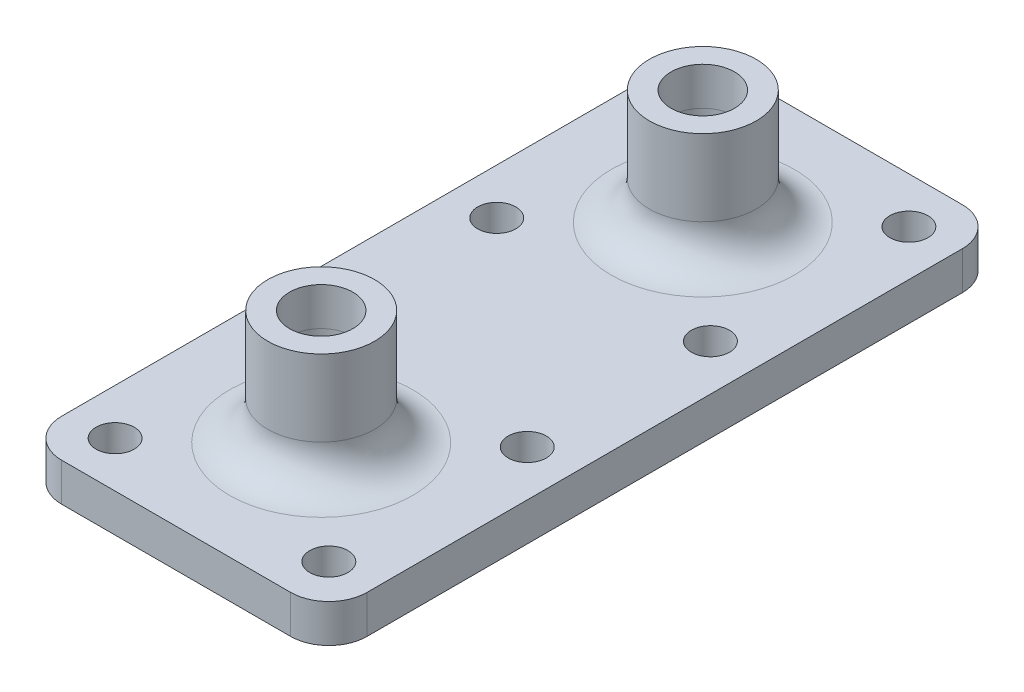
from build123d import *

# Parameters (mm, degrees)
SKETCH1_W             = 40
SKETCH1_H             = 88
SKETCH1_R             = 2.5
BOSS_EXTRUDE1_DEPTH   = 5
SKETCH2_R             = 7
SKETCH2_R_2           = 4.15
BOSS_EXTRUDE2_DEPTH   = 20
CHAMFER1_SIZE         = 10
CHAMFER1_SIZE2        = 0.174550649
CHAMFER1_PART_2_SIZE  = 10
CHAMFER1_PART_2_SIZE2 = 0.174550649
FILLET1_R             = 5


with BuildPart() as part:
    # Sketch1 → Boss-Extrude1 (new body)
    with BuildSketch(Plane(origin=(0, 0, 0), x_dir=(1, 0, 0), z_dir=(0, 1, 0))):
        Rectangle(SKETCH1_W, SKETCH1_H)
        with Locations((-14, 38)):
            Circle(SKETCH1_R, mode=Mode.SUBTRACT)
        with Locations((14, 38)):
            Circle(SKETCH1_R, mode=Mode.SUBTRACT)
        with Locations((-14, 12)):
            Circle(SKETCH1_R, mode=Mode.SUBTRACT)
        with Locations((14, 12)):
            Circle(SKETCH1_R, mode=Mode.SUBTRACT)
        with Locations((-14, -12)):
            Circle(SKETCH1_R, mode=Mode.SUBTRACT)
        with Locations((-14, -38)):
            Circle(SKETCH1_R, mode=Mode.SUBTRACT)
        with Locations((14, -38)):
            Circle(SKETCH1_R, mode=Mode.SUBTRACT)
        with Locations((14, -12)):
            Circle(SKETCH1_R, mode=Mode.SUBTRACT)
    extrude(amount=BOSS_EXTRUDE1_DEPTH)

    # Sketch2 → Boss-Extrude2 (add)
    with BuildSketch(Plane(origin=(0, 0, 0), x_dir=(1, 0, 0), z_dir=(0, 1, 0))):
        with Locations((0, 25)):
            Circle(SKETCH2_R)
        with Locations((0, 25)):
            Circle(SKETCH2_R_2, mode=Mode.SUBTRACT)
        with Locations((0, -25)):
            Circle(SKETCH2_R)
        with Locations((0, -25)):
            Circle(SKETCH2_R_2, mode=Mode.SUBTRACT)
    extrude(amount=BOSS_EXTRUDE2_DEPTH)

    # Chamfer1
    chamfer1_edges = [part.edges().sort_by_distance(p)[0] for p in [
        (-4.15, 5, 25),
    ]]
    chamfer1_side = [part.faces().sort_by_distance(p)[0] for p in [
        (-4.15, 12.5, 25),
    ]]
    chamfer(chamfer1_edges, length=CHAMFER1_SIZE, length2=CHAMFER1_SIZE2, reference=chamfer1_side[0])

    # Chamfer1 part 2
    chamfer1_part_2_edges = [part.edges().sort_by_distance(p)[0] for p in [
        (-4.15, 5, -25),
    ]]
    chamfer1_part_2_side = [part.faces().sort_by_distance(p)[0] for p in [
        (-4.15, 12.5, -25),
    ]]
    chamfer(chamfer1_part_2_edges, length=CHAMFER1_PART_2_SIZE, length2=CHAMFER1_PART_2_SIZE2, reference=chamfer1_part_2_side[0])

    # Fillet1
    fillet1_edges = [part.edges().sort_by_distance(p)[0] for p in [
        (-7, 5, 25),
        (-7, 5, -25),
        (-20, 2.5, -44),
        (20, 2.5, -44),
        (20, 2.5, 44),
        (-20, 2.5, 44),
    ]]
    fillet(fillet1_edges, radius=FILLET1_R)


solid = part.part
